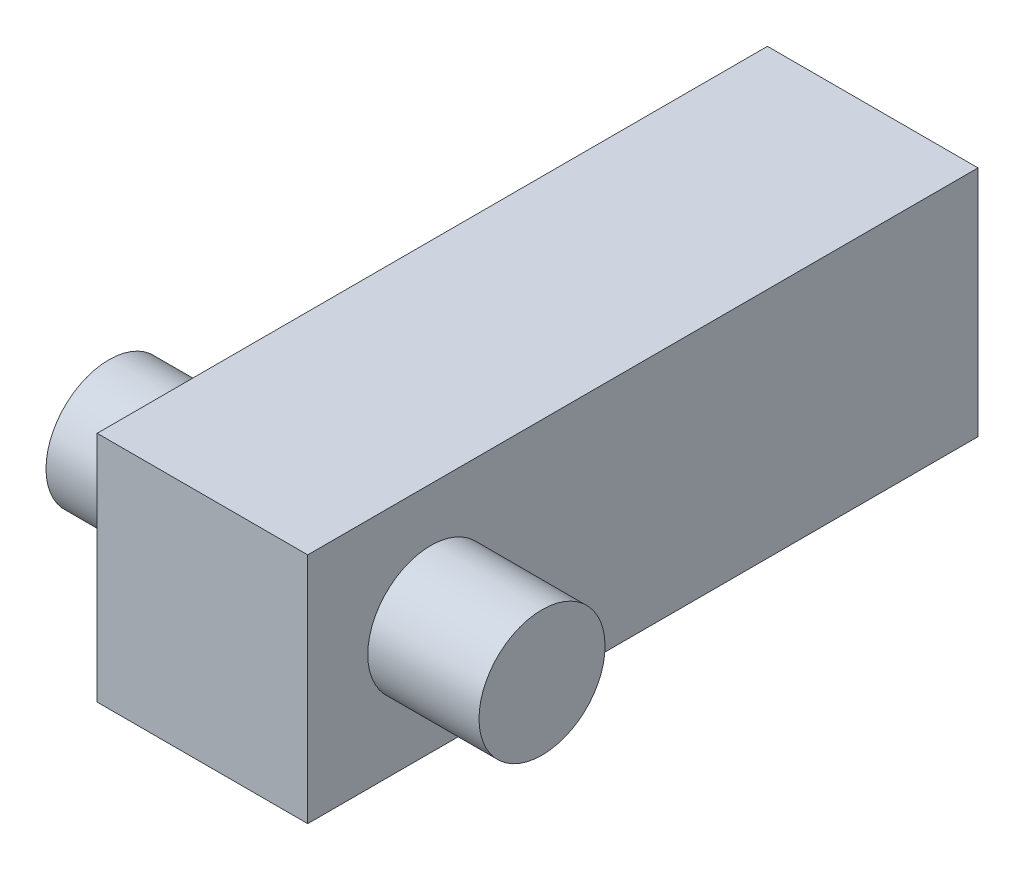
from build123d import *

# Parameters (mm, degrees)
SKETCH1_W           = 36.068
SKETCH1_H           = 114.808
BOSS_EXTRUDE1_DEPTH = 39.878
SKETCH3_R           = 10.795
BOSS_EXTRUDE2_DEPTH = 19.05
SKETCH4_R           = 10.795
BOSS_EXTRUDE4_DEPTH = 19.05


with BuildPart() as part:
    # Sketch1 → Boss-Extrude1 (new body)
    with BuildSketch(Plane(origin=(0, 0, 0), x_dir=(1, 0, 0), z_dir=(0, 1, 0))):
        with Locations((18.034, 57.404)):
            Rectangle(SKETCH1_W, SKETCH1_H)
    extrude(amount=BOSS_EXTRUDE1_DEPTH)

    # Sketch3 → Boss-Extrude2 (add)
    with BuildSketch(Plane.ZY):
        with Locations((-21.082, 19.939)):
            Circle(SKETCH3_R)
    extrude(amount=BOSS_EXTRUDE2_DEPTH)

    # Sketch4 → Boss-Extrude4 (add)
    with BuildSketch(Plane(origin=(36.068, 0, 0), x_dir=(0, 0, -1), z_dir=(1, 0, 0))):
        with Locations((21.082, 19.939)):
            Circle(SKETCH4_R)
    extrude(amount=BOSS_EXTRUDE4_DEPTH)


solid = part.part
